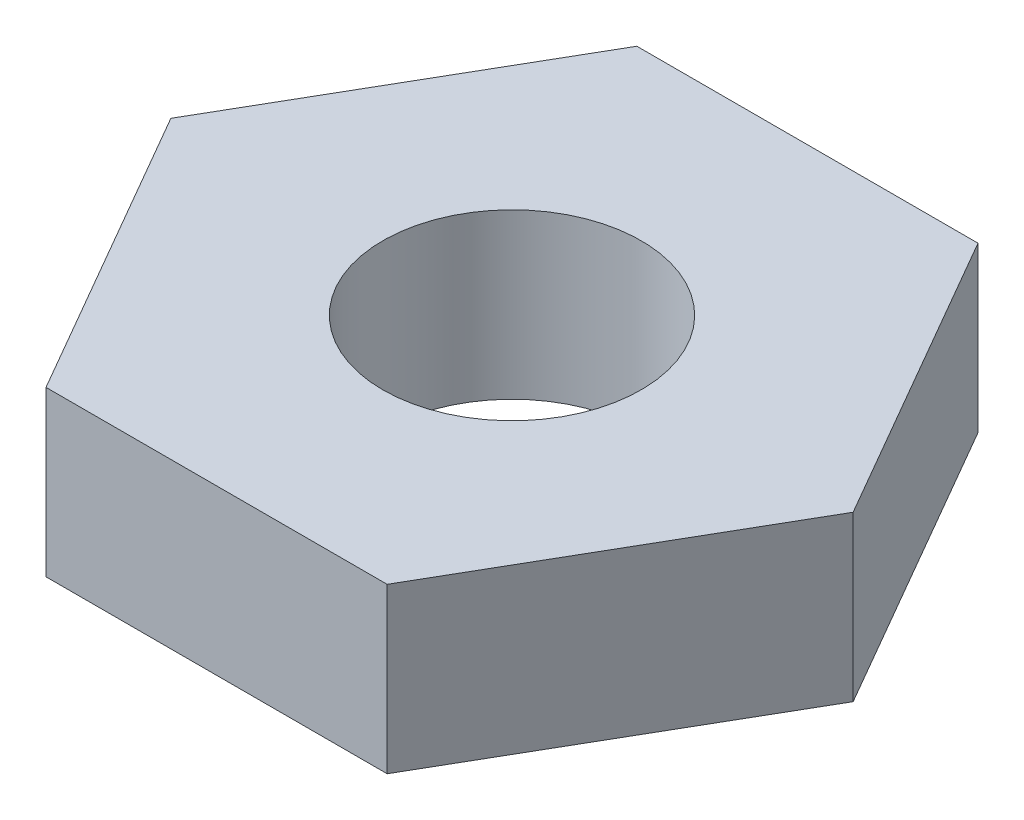
from build123d import *

# Parameters (mm, degrees)
SKETCH1_R           = 1.5
BOSS_EXTRUDE1_DEPTH = 1.905


with BuildPart() as part:
    # Sketch1 → Boss-Extrude1 (new body)
    with BuildSketch(Plane(origin=(0, 0, 0), x_dir=(1, 0, 0), z_dir=(0, 1, 0))):
        Polygon((-1.980311423, -3.43), (1.980311423, -3.43), (3.960622847, 0), (1.980311423, 3.43), (-1.980311423, 3.43), (-3.960622847, 0), align=None)
        Circle(SKETCH1_R, mode=Mode.SUBTRACT)
    extrude(amount=BOSS_EXTRUDE1_DEPTH)


solid = part.part
